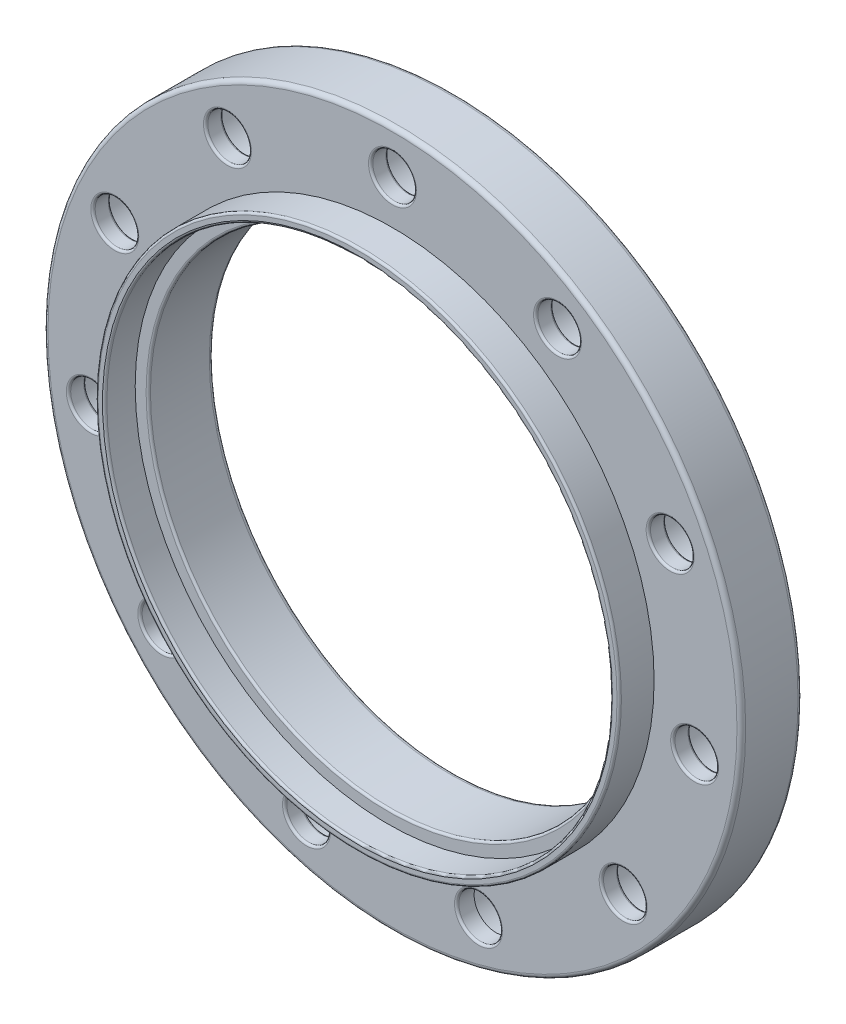
from build123d import *

# Parameters (mm, degrees)
SKETCH1_R           = 40
SKETCH1_R_2         = 29
BOSS_EXTRUDE1_DEPTH = 10
SKETCH2_R           = 30
SKETCH2_R_2         = 29
BOSS_EXTRUDE2_DEPTH = 4
SKETCH3_R           = 29
SKETCH3_R_2         = 27.5
BOSS_EXTRUDE3_DEPTH = 10.5
SKETCH4_R           = 2.5
CUT_EXTRUDE1_DEPTH  = 15
SKETCH5_R           = 40
SKETCH5_R_2         = 27.5
CUT_EXTRUDE2_DEPTH  = 3
SKETCH6_R           = 4.125
CUT_EXTRUDE3_DEPTH  = 5
FILLET1_R           = 0.5
FILLET2_R           = 0.25


with BuildPart() as part:
    # Sketch1 → Boss-Extrude1 (new body)
    with BuildSketch(Plane.XY):
        Circle(SKETCH1_R)
        Circle(SKETCH1_R_2, mode=Mode.SUBTRACT)
    extrude(amount=BOSS_EXTRUDE1_DEPTH)

    # Sketch2 → Boss-Extrude2 (add)
    with BuildSketch(Plane.XY.offset(10)):
        Circle(SKETCH2_R)
        Circle(SKETCH2_R_2, mode=Mode.SUBTRACT)
    extrude(amount=BOSS_EXTRUDE2_DEPTH)

    # Sketch3 → Boss-Extrude3 (add)
    with BuildSketch(Plane(origin=(0, 0, 0), x_dir=(-1, 0, 0), z_dir=(0, 0, -1))):
        Circle(SKETCH3_R)
        Circle(SKETCH3_R_2, mode=Mode.SUBTRACT)
    extrude(amount=-BOSS_EXTRUDE3_DEPTH)

    # Sketch4 → Cut-Extrude1 (cut, through all)
    with BuildSketch(Plane(origin=(0, 0, 0), x_dir=(-1, 0, 0), z_dir=(0, 0, -1))):
        with Locations((0, 35)):
            Circle(SKETCH4_R)
        with Locations((18.922428611, 29.443873649)):
            Circle(SKETCH4_R)
        with Locations((31.837119837, 14.539525455)):
            Circle(SKETCH4_R)
        with Locations((34.643750466, -4.98101934)):
            Circle(SKETCH4_R)
        with Locations((26.451235102, -22.920125688)):
            Circle(SKETCH4_R)
        with Locations((9.860639489, -33.582254077)):
            Circle(SKETCH4_R)
        with Locations((-9.860639489, -33.582254077)):
            Circle(SKETCH4_R)
        with Locations((-26.451235102, -22.920125688)):
            Circle(SKETCH4_R)
        with Locations((-34.643750466, -4.98101934)):
            Circle(SKETCH4_R)
        with Locations((-31.837119837, 14.539525455)):
            Circle(SKETCH4_R)
        with Locations((-18.922428611, 29.443873649)):
            Circle(SKETCH4_R)
    extrude(amount=-CUT_EXTRUDE1_DEPTH, mode=Mode.SUBTRACT)

    # Sketch5 → Cut-Extrude2 (cut)
    with BuildSketch(Plane(origin=(0, 0, 0), x_dir=(-1, 0, 0), z_dir=(0, 0, -1))):
        Circle(SKETCH5_R)
        Circle(SKETCH5_R_2, mode=Mode.SUBTRACT)
    extrude(amount=-CUT_EXTRUDE2_DEPTH, mode=Mode.SUBTRACT)

    # Sketch6 → Cut-Extrude3 (cut)
    with BuildSketch(Plane(origin=(0, 0, 3), x_dir=(-1, 0, 0), z_dir=(0, 0, -1))):
        with Locations((0, 35)):
            Circle(SKETCH6_R)
        with Locations((18.922428611, 29.443873649)):
            Circle(SKETCH6_R)
        with Locations((31.837119837, 14.539525455)):
            Circle(SKETCH6_R)
        with Locations((34.643750466, -4.98101934)):
            Circle(SKETCH6_R)
        with Locations((26.451235102, -22.920125688)):
            Circle(SKETCH6_R)
        with Locations((9.860639489, -33.582254077)):
            Circle(SKETCH6_R)
        with Locations((-9.860639489, -33.582254077)):
            Circle(SKETCH6_R)
        with Locations((-26.451235102, -22.920125688)):
            Circle(SKETCH6_R)
        with Locations((-34.643750466, -4.98101934)):
            Circle(SKETCH6_R)
        with Locations((-31.837119837, 14.539525455)):
            Circle(SKETCH6_R)
        with Locations((-18.922428611, 29.443873649)):
            Circle(SKETCH6_R)
    extrude(amount=-CUT_EXTRUDE3_DEPTH, mode=Mode.SUBTRACT)

    # Fillet1
    fillet1_edges = [part.edges().sort_by_distance(p)[0] for p in [
        (-40, 0, 10),
        (27.5, 0, 3),
        (-40, 0, 3),
    ]]
    fillet(fillet1_edges, radius=FILLET1_R)

    # Fillet2
    fillet2_edges = [part.edges().sort_by_distance(p)[0] for p in [
        (-30, 0, 14),
        (-29, 0, 14),
        (-14.797428611, 29.443873649, 3),
        (-16.422428611, 29.443873649, 8),
        (-27.712119837, 14.539525455, 3),
        (-29.337119837, 14.539525455, 8),
        (-30.518750466, -4.98101934, 3),
        (-32.143750466, -4.98101934, 8),
        (-22.326235102, -22.920125688, 3),
        (-23.951235102, -22.920125688, 8),
        (-5.735639489, -33.582254077, 3),
        (-7.360639489, -33.582254077, 8),
        (13.985639489, -33.582254077, 3),
        (30.576235102, -22.920125688, 3),
        (28.951235102, -22.920125688, 8),
        (38.768750466, -4.98101934, 3),
        (37.143750466, -4.98101934, 8),
        (35.962119837, 14.539525455, 3),
        (34.337119837, 14.539525455, 8),
        (23.047428611, 29.443873649, 3),
        (21.422428611, 29.443873649, 8),
        (4.125, 35, 3),
        (2.5, 35, 8),
        (27.5, 0, 10.5),
        (2.5, 35, 10),
        (21.422428611, 29.443873649, 10),
        (34.337119837, 14.539525455, 10),
        (37.143750466, -4.98101934, 10),
        (28.951235102, -22.920125688, 10),
        (12.360639489, -33.582254077, 10),
        (-7.360639489, -33.582254077, 10),
        (-23.951235102, -22.920125688, 10),
        (-32.143750466, -4.98101934, 10),
        (-29.337119837, 14.539525455, 10),
        (-16.422428611, 29.443873649, 10),
    ]]
    fillet(fillet2_edges, radius=FILLET2_R)


solid = part.part
